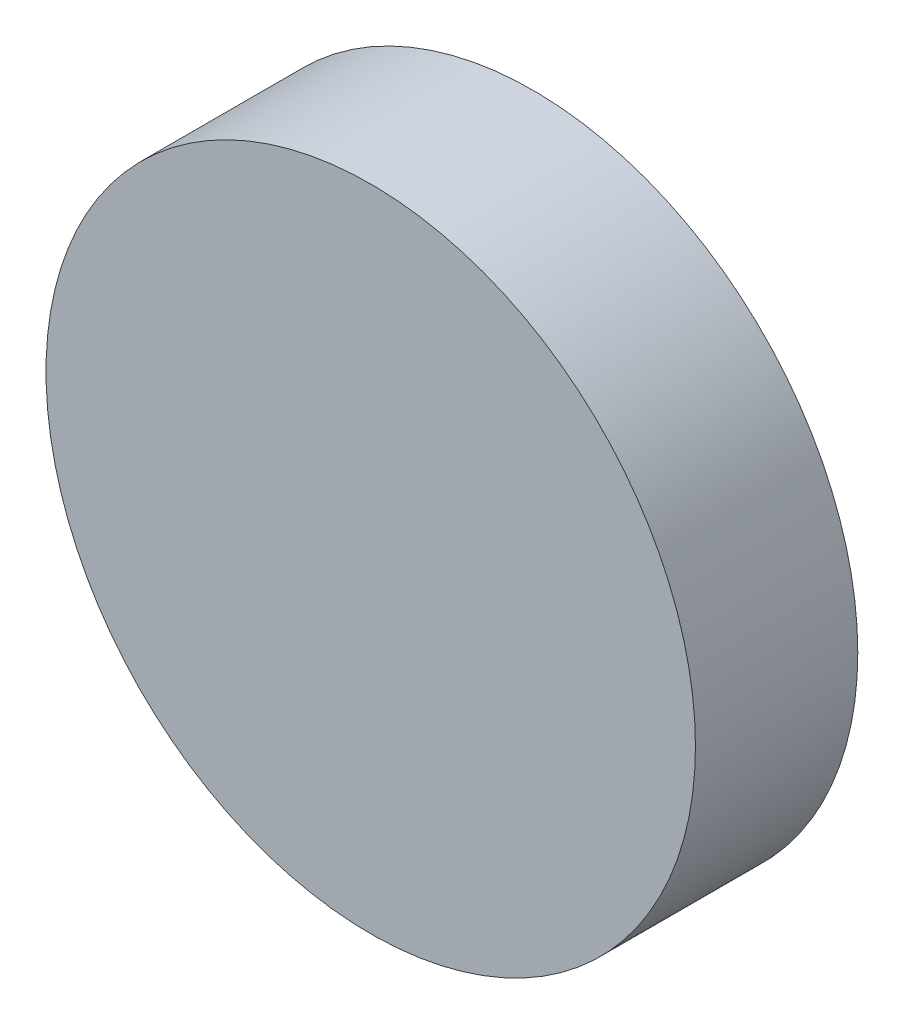
from build123d import *

# Parameters (mm, degrees)
SKETCH1_R           = 2
BOSS_EXTRUDE1_DEPTH = 0.5


with BuildPart() as part:
    # Sketch1 → Boss-Extrude1 (new body, symmetric)
    with BuildSketch(Plane.XY):
        Circle(SKETCH1_R)
    extrude(amount=BOSS_EXTRUDE1_DEPTH, both=True)


solid = part.part
